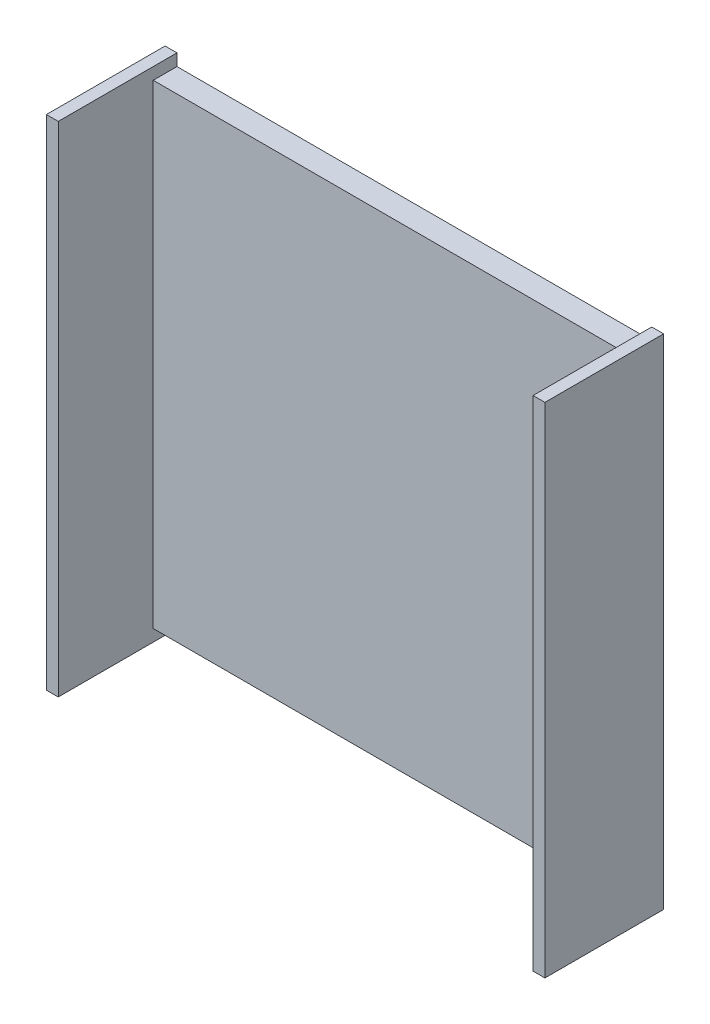
from build123d import *

# Parameters (mm, degrees)
SKETCH1_W           = 42
SKETCH1_H           = 42
SKETCH1_W_2         = 40
SKETCH1_H_2         = 40
BOSS_EXTRUDE1_DEPTH = 10
SKETCH3_W           = 2
SKETCH3_H           = 40
BOSS_EXTRUDE2_DEPTH = 40
SKETCH5_W           = 40
SKETCH5_H           = 1
CUT_EXTRUDE1_DEPTH  = 10
SKETCH6_W           = 40
SKETCH6_H           = 1
CUT_EXTRUDE2_DEPTH  = 10


with BuildPart() as part:
    # Sketch1 → Boss-Extrude1 (new body)
    with BuildSketch(Plane.XY):
        Rectangle(SKETCH1_W, SKETCH1_H)
        Rectangle(SKETCH1_W_2, SKETCH1_H_2, mode=Mode.SUBTRACT)
    extrude(amount=BOSS_EXTRUDE1_DEPTH)

    # Sketch3 → Boss-Extrude2 (add)
    with BuildSketch(Plane(origin=(-20, 0, 0), x_dir=(0, 0, -1), z_dir=(1, 0, 0))):
        with Locations((-1, 0)):
            Rectangle(SKETCH3_W, SKETCH3_H)
    extrude(amount=BOSS_EXTRUDE2_DEPTH)

    # Sketch5 → Cut-Extrude1 (cut)
    with BuildSketch(Plane.XY.offset(10)):
        with Locations((0, 20.5)):
            Rectangle(SKETCH5_W, SKETCH5_H)
    extrude(amount=-CUT_EXTRUDE1_DEPTH, mode=Mode.SUBTRACT)

    # Sketch6 → Cut-Extrude2 (cut)
    with BuildSketch(Plane.XY.offset(10)):
        with Locations((0, -20.5)):
            Rectangle(SKETCH6_W, SKETCH6_H)
    extrude(amount=-CUT_EXTRUDE2_DEPTH, mode=Mode.SUBTRACT)


solid = part.part
